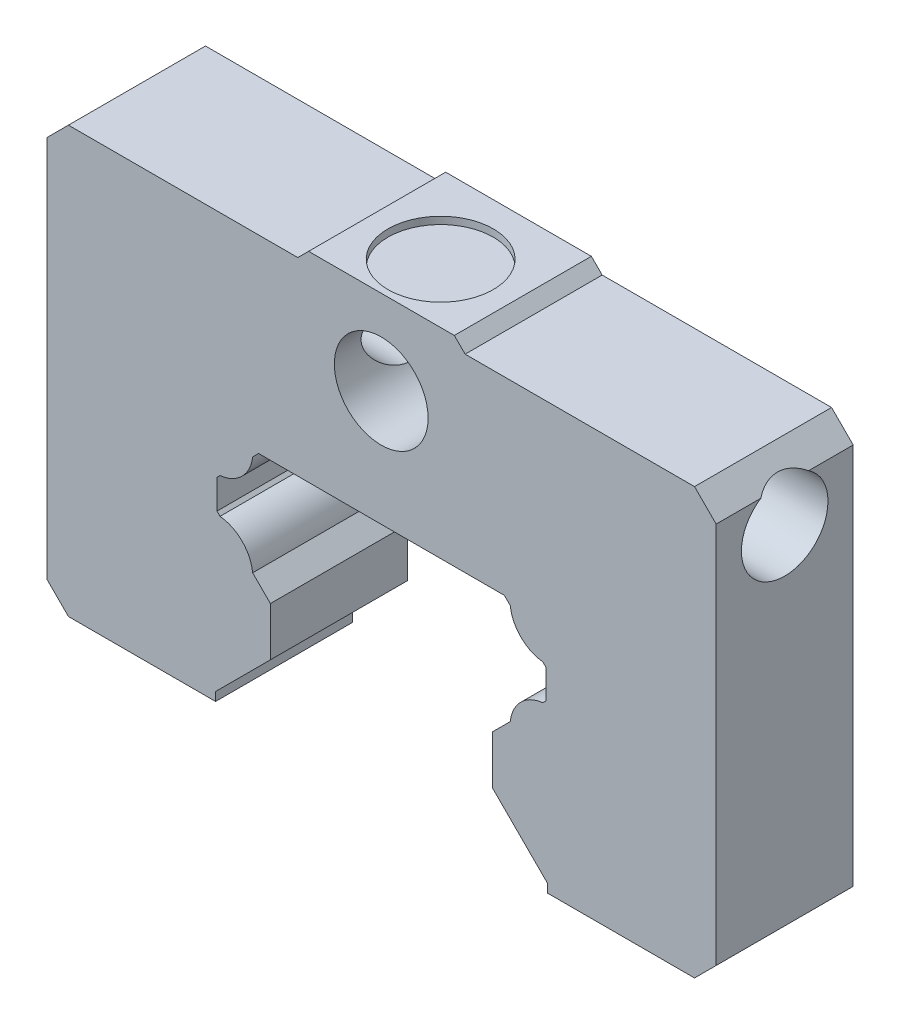
from build123d import *

# Parameters (mm, degrees)
ENDCAP_1_DEPTH                  = 9.5
TAP_DRILL_FOR_M6X1_0_TAP1_D     = 6.5
TAP_DRILL_FOR_M6X1_0_TAP1_DEPTH = 12.5
TAP_DRILL_FOR_M6X1_0_TAP1_TIP   = 1.691842914
TAP_DRILL_FOR_M6X1_0_TAP2_D     = 6
SKETCH9_R                       = 3.65
CUT_EXTRUDE1_DEPTH              = 0.5


with BuildPart() as part:
    # Sketch3 → Endcap 1 (new body)
    with BuildSketch(Plane.XY):
        with BuildLine():
            Line((-21.7, 0), (-11.5, 0))
            Line((-11.5, 0), (-11.5, 0.6))
            Line((-11.5, 0.6), (-7.7, 4.4))
            Line((-7.7, 4.4), (-7.7, 7.78))
            Line((-7.7, 7.78), (-8.93, 9.01))
            ThreePointArc((-8.93, 9.01), (-9.658631808, 10.541368192), (-11.19, 11.27))
            Line((-11.19, 11.27), (-11.4, 11.48))
            Line((-11.4, 11.48), (-11.4, 13.51))
            Line((-11.4, 13.51), (-11.19, 13.719070796))
            ThreePointArc((-11.19, 13.719070796), (-9.661781613, 14.44408255), (-8.93, 15.969070796))
            Line((-8.93, 15.969070796), (-8.518177778, 16.379070796))
            Line((-8.518177778, 16.379070796), (8.518177778, 16.379070796))
            Line((8.518177778, 16.379070796), (8.93, 15.969070796))
            ThreePointArc((8.93, 15.969070796), (9.661781613, 14.44408255), (11.19, 13.719070796))
            Line((11.19, 13.719070796), (11.4, 13.51))
            Line((11.4, 13.51), (11.4, 11.48))
            Line((11.4, 11.48), (11.19, 11.27))
            ThreePointArc((11.19, 11.27), (9.658631808, 10.541368192), (8.93, 9.01))
            Line((8.93, 9.01), (7.7, 7.78))
            Line((7.7, 7.78), (7.7, 4.4))
            Line((7.7, 4.4), (11.5, 0.6))
            Line((11.5, 0.6), (11.5, 0))
            Line((11.5, 0), (21.7, 0))
            Line((21.7, 0), (23.2, 1.5))
            Line((23.2, 1.5), (23.2, 28))
            Line((23.2, 28), (21.7, 29.5))
            Line((21.7, 29.5), (5.8, 29.5))
            Line((5.8, 29.5), (5.05, 30.25))
            Line((5.05, 30.25), (-5.05, 30.25))
            Line((-5.05, 30.25), (-5.8, 29.5))
            Line((-5.8, 29.5), (-21.7, 29.5))
            Line((-21.7, 29.5), (-23.2, 28))
            Line((-23.2, 28), (-23.2, 1.5))
            Line((-23.2, 1.5), (-21.7, 0))
        make_face()
    extrude(amount=ENDCAP_1_DEPTH)

    # Tap Drill for M6x1.0 Tap1
    with Locations(Plane.XY.offset(9.5)):
        with Locations((-0.017990465, 24.379070796)):
            Hole(TAP_DRILL_FOR_M6X1_0_TAP1_D / 2, depth=TAP_DRILL_FOR_M6X1_0_TAP1_DEPTH)
            with Locations((0, 0, -(TAP_DRILL_FOR_M6X1_0_TAP1_DEPTH + TAP_DRILL_FOR_M6X1_0_TAP1_TIP / 2))):  # 125° drill point
                Cone(0, TAP_DRILL_FOR_M6X1_0_TAP1_D / 2, TAP_DRILL_FOR_M6X1_0_TAP1_TIP, mode=Mode.SUBTRACT)

    # Tap Drill for M6x1.0 Tap2 (through all)
    with Locations(Plane(origin=(23.2, 0, 0), x_dir=(0, 0, -1), z_dir=(1, 0, 0))):
        with Locations((-4.75, 25.5)):
            Hole(TAP_DRILL_FOR_M6X1_0_TAP2_D / 2)

    # Sketch9 → Cut-Extrude1 (cut)
    with BuildSketch(Plane(origin=(0, 30.25, 0), x_dir=(1, 0, 0), z_dir=(0, 1, 0))):
        with Locations((0, -5.399368506)):
            Circle(SKETCH9_R)
    extrude(amount=-CUT_EXTRUDE1_DEPTH, mode=Mode.SUBTRACT)


solid = part.part
